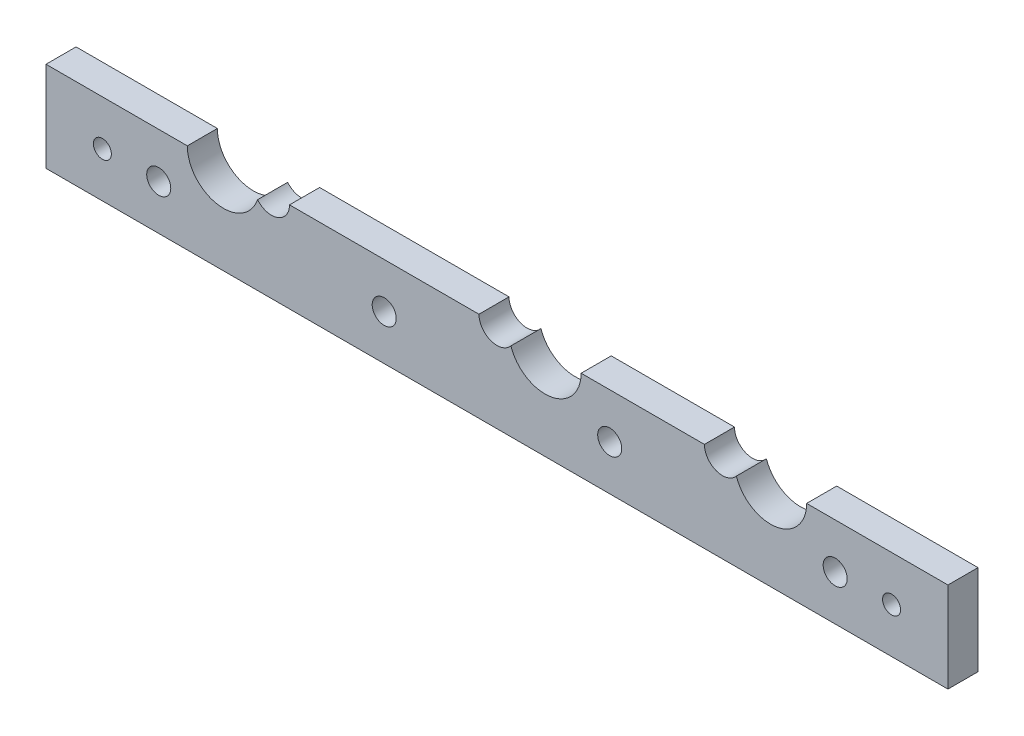
from build123d import *

# Parameters (mm, degrees)
SKETCH1_W                      = 150
SKETCH1_H                      = 30
BOSS_EXTRUDE1_DEPTH            = 5
F_6_0MM_DOWEL_HOLE1_AT_2_COUNT = 2
F_6_0MM_DOWEL_HOLE1_AT_2_PITCH = 37.5
F_4_0MM_DOWEL_HOLE1_AT_2_COUNT = 2
F_4_0MM_DOWEL_HOLE1_AT_2_PITCH = 37.5
F_12_0MM_DOWEL_HOLE2_D         = 12
F_12_0MM_DOWEL_HOLE2_DEPTH     = 25
F_12_0MM_DOWEL_HOLE2_TIP       = 3.605163714
SKETCH30_W                     = 150
SKETCH30_H                     = 15
CUT_EXTRUDE1_DEPTH             = 10
F_12_0MM_DOWEL_HOLE3_D         = 12
F_12_0MM_DOWEL_HOLE3_DEPTH     = 12.75
F_12_0MM_DOWEL_HOLE3_TIP       = 3.605163714


with BuildPart() as part:
    # Sketch1 → Boss-Extrude1 (new body)
    with BuildSketch(Plane.XY):
        with Locations((18.189254194, 3.553058878)):
            Rectangle(SKETCH1_W, SKETCH1_H)
    extrude(amount=BOSS_EXTRUDE1_DEPTH)

    # Sketch4 → Ø6.0mm Dowel Hole1 (revolve, cut)
    with BuildSketch(Plane(origin=(55.689254194, 3.553058878, 5), x_dir=(0, -1, 0), z_dir=(1, 0, 0))):
        Polygon((0, 0), (0, 26.802581857), (3, 25), (3, 0), align=None)
    f_6_0mm_dowel_hole1 = revolve(axis=Axis((55.689254194, 3.553058878, 11.35), (0, 0, -1)), mode=Mode.SUBTRACT)

    # Ø6.0mm Dowel Hole1 at 2: Ø6.0mm Dowel Hole1 ×2
    with Locations(*[(-i * F_6_0MM_DOWEL_HOLE1_AT_2_PITCH, 0, 0) for i in range(1, F_6_0MM_DOWEL_HOLE1_AT_2_COUNT)]):
        add(f_6_0mm_dowel_hole1, mode=Mode.SUBTRACT)

    # Mirror1: Ø6.0mm Dowel Hole1 across plane
    add(f_6_0mm_dowel_hole1.mirror(Plane.ZY.offset(-18.189254194)), mode=Mode.SUBTRACT)

    # Mirror1 copy 1 sketch → Mirror1 copy 1 (revolve, cut)
    with BuildSketch(Plane(origin=(18.189254194, 3.553058878, 5), x_dir=(0, -1, 0), z_dir=(-1, 0, 0))):
        Polygon((0, 0), (0, -26.802581857), (3, -25), (3, 0), align=None)
    revolve(axis=Axis((18.189254194, 3.553058878, 11.35), (0, 0, 1)), mode=Mode.SUBTRACT)

    # Sketch6 → Ø4.0mm Dowel Hole1 (revolve, cut)
    with BuildSketch(Plane(origin=(74.439254194, 11.053058878, 5), x_dir=(0, -1, 0), z_dir=(1, 0, 0))):
        Polygon((0, 0), (0, 26.201721238), (2, 25), (2, 0), align=None)
    f_4_0mm_dowel_hole1 = revolve(axis=Axis((74.439254194, 11.053058878, 11.35), (0, 0, -1)), mode=Mode.SUBTRACT)

    # Ø4.0mm Dowel Hole1 at 2: Ø4.0mm Dowel Hole1 ×2
    with Locations(*[(-i * F_4_0MM_DOWEL_HOLE1_AT_2_PITCH, 0, 0) for i in range(1, F_4_0MM_DOWEL_HOLE1_AT_2_COUNT)]):
        add(f_4_0mm_dowel_hole1, mode=Mode.SUBTRACT)

    # Mirror2: Ø4.0mm Dowel Hole1 across plane
    add(f_4_0mm_dowel_hole1.mirror(Plane.ZX.offset(3.553058878)), mode=Mode.SUBTRACT)

    # Mirror2 copy 1 sketch → Mirror2 copy 1 (revolve, cut)
    with BuildSketch(Plane(origin=(36.939254194, -3.946941122, 5), x_dir=(0, 1, 0), z_dir=(1, 0, 0))):
        Polygon((0, 0), (0, -26.201721238), (2, -25), (2, 0), align=None)
    revolve(axis=Axis((36.939254194, -3.946941122, 11.35), (0, 0, 1)), mode=Mode.SUBTRACT)

    # Mirror3: Ø4.0mm Dowel Hole1 across plane
    add(f_4_0mm_dowel_hole1.mirror(Plane.ZY.offset(-18.189254194)), mode=Mode.SUBTRACT)

    # Mirror3 copy 1 sketch → Mirror3 copy 1 (revolve, cut)
    with BuildSketch(Plane(origin=(-38.060745806, -3.946941122, 5), x_dir=(0, 1, 0), z_dir=(-1, 0, 0))):
        Polygon((0, 0), (0, 26.201721238), (2, 25), (2, 0), align=None)
    revolve(axis=Axis((-38.060745806, -3.946941122, 11.35), (0, 0, -1)), mode=Mode.SUBTRACT)

    # Mirror3 copy 2 sketch → Mirror3 copy 2 (revolve, cut)
    with BuildSketch(Plane(origin=(-0.560745806, -3.946941122, 5), x_dir=(0, 1, 0), z_dir=(-1, 0, 0))):
        Polygon((0, 0), (0, 26.201721238), (2, 25), (2, 0), align=None)
    revolve(axis=Axis((-0.560745806, -3.946941122, 11.35), (0, 0, -1)), mode=Mode.SUBTRACT)

    # Mirror3 copy 3 sketch → Mirror3 copy 3 (revolve, cut)
    with BuildSketch(Plane(origin=(-0.560745806, 11.053058878, 5), x_dir=(0, -1, 0), z_dir=(-1, 0, 0))):
        Polygon((0, 0), (0, -26.201721238), (2, -25), (2, 0), align=None)
    revolve(axis=Axis((-0.560745806, 11.053058878, 11.35), (0, 0, 1)), mode=Mode.SUBTRACT)

    # Sketch23 → Ø3.0mm Dowel Hole2 (revolve, cut)
    with BuildSketch(Plane(origin=(-47.435745806, -3.946941122, 5), x_dir=(0, -1, 0), z_dir=(1, 0, 0))):
        Polygon((0, 0), (0, 25.901290929), (1.5, 25), (1.5, 0), align=None)
    f_3_0mm_dowel_hole2 = revolve(axis=Axis((-47.435745806, -3.946941122, 11.35), (0, 0, -1)), mode=Mode.SUBTRACT)

    # Mirror5: Ø3.0mm Dowel Hole2 across plane
    add(f_3_0mm_dowel_hole2.mirror(Plane.ZY.offset(-18.189254194)), mode=Mode.SUBTRACT)

    # Ø12.0mm Dowel Hole2
    with Locations(Plane(origin=(26.189254194, 3.553058878, 5), x_dir=(1, 0, 0), z_dir=(0, 0, 1))):
        with Locations((0, 0)):
            Hole(F_12_0MM_DOWEL_HOLE2_D / 2, depth=F_12_0MM_DOWEL_HOLE2_DEPTH)
            with Locations((0, 0, -(F_12_0MM_DOWEL_HOLE2_DEPTH + F_12_0MM_DOWEL_HOLE2_TIP / 2))):  # 118° drill point
                Cone(0, F_12_0MM_DOWEL_HOLE2_D / 2, F_12_0MM_DOWEL_HOLE2_TIP, mode=Mode.SUBTRACT)

    # Sketch30 → Cut-Extrude1 (cut)
    with BuildSketch(Plane.XY.offset(5)):
        with Locations((18.189254194, 11.053058878)):
            Rectangle(SKETCH30_W, SKETCH30_H)
    extrude(amount=-CUT_EXTRUDE1_DEPTH, mode=Mode.SUBTRACT)

    # Ø12.0mm Dowel Hole3
    with Locations(Plane.XY.offset(5)):
        with Locations((63.689254194, 3.553058878), (-27.310745806, 3.553058878)):
            Hole(F_12_0MM_DOWEL_HOLE3_D / 2, depth=F_12_0MM_DOWEL_HOLE3_DEPTH)
            with Locations((0, 0, -(F_12_0MM_DOWEL_HOLE3_DEPTH + F_12_0MM_DOWEL_HOLE3_TIP / 2))):  # 118° drill point
                Cone(0, F_12_0MM_DOWEL_HOLE3_D / 2, F_12_0MM_DOWEL_HOLE3_TIP, mode=Mode.SUBTRACT)


solid = part.part
